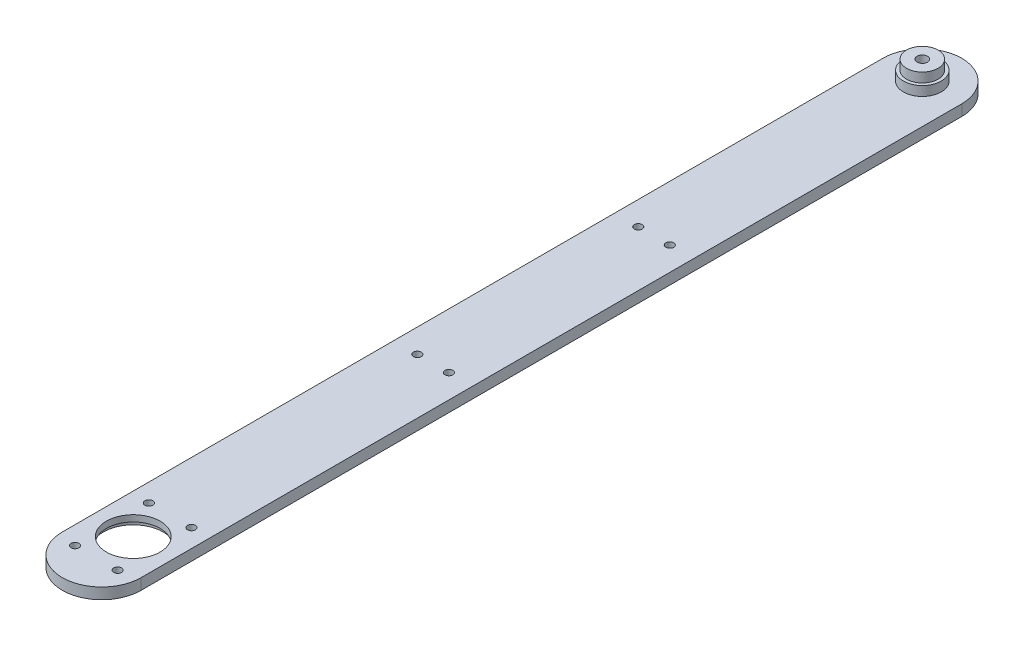
from build123d import *

# Parameters (mm, degrees)
EXTRUDE_1_DEPTH             = 10.5
EXTRUDE_1_DEPTH_BACK        = 10.5
SKETCH_1_R                  = 5
EXTRUDE_3_DEPTH             = 4.5
EXTRUDE_3_DEPTH_BACK        = 4.5
SKETCH_7_R                  = 6
EXTRUDE_4_DEPTH             = 3
EXTRUDE_START               = 3
SKETCH_8_R                  = 6
EXTRUDE_5_DEPTH             = 3
SKETCH_9_R                  = 9.5
CUT_EXTRUDE_1_DEPTH         = 7
SKETCH_10_R                 = 8.5
CUT_EXTRUDE_2_DEPTH         = 274.096136919
HOLE_WIZARD_M4_1_D          = 3.3
SKETCH_22_W                 = 46.630089335
SKETCH_22_H                 = 20.014444788
CUT_EXTRUDE_3_DEPTH         = 1111
HOLE_WIZARD_M3_2_D          = 2.5
PATTERN_LINEAR_1_COUNT      = 3
PATTERN_LINEAR_1_PITCH      = 70
PATTERN_LINEAR_1_COUNT_DIR2 = 2
PATTERN_LINEAR_1_PITCH_DIR2 = 10
HOLE_WIZARD_M3_1_D          = 2.5
PATTERN_CIRCULAR_1_COUNT    = 6
EXTRUDE_START_2             = -3.5
SKETCH_32_R                 = 1.25
EXTRUDE_6_DEPTH             = 3.5


with BuildPart() as part:
    # 스케치1 → 보스-돌출1 (new, two sides: drawn at the far end of the back side and taken through both)
    with BuildSketch(Plane(origin=(0, 0, 0), x_dir=(1, 0, 0), z_dir=(0, 1, 0)).offset(-EXTRUDE_1_DEPTH_BACK)):
        Circle(SKETCH_1_R)
    extrude(amount=EXTRUDE_1_DEPTH + EXTRUDE_1_DEPTH_BACK)

    # 스케치6 → 보스-돌출3 (add, two sides: drawn at the far end of the back side and taken through both)
    with BuildSketch(Plane(origin=(0, 0, 0), x_dir=(1, 0, 0), z_dir=(0, 1, 0)).offset(-EXTRUDE_3_DEPTH_BACK)):
        with BuildLine():
            Line((-12.5, 0), (-12.5, -260))
            ThreePointArc((-12.5, -260), (0, -272.5), (12.5, -260))
            Line((12.5, -260), (12.5, 0))
            ThreePointArc((12.5, 0), (0, 12.5), (-12.5, 0))
        make_face()
    extrude(amount=EXTRUDE_3_DEPTH + EXTRUDE_3_DEPTH_BACK)

    # 스케치7 → 보스-돌출4 (add)
    with BuildSketch(Plane.XZ.offset(4.5)):
        Circle(SKETCH_7_R)
    extrude(amount=EXTRUDE_4_DEPTH)

    # 스케치8 → 보스-돌출5 (add)
    with BuildSketch(Plane(origin=(0, 4.5, 0), x_dir=(1, 0, 0), z_dir=(0, 1, 0)).offset(EXTRUDE_START)):
        Circle(SKETCH_8_R)
    extrude(amount=-EXTRUDE_5_DEPTH)

    # 스케치9 → 컷-돌출1 (cut)
    with BuildSketch(Plane.XZ.offset(4.5)):
        with Locations((0, 250)):
            Circle(SKETCH_9_R)
    extrude(amount=-CUT_EXTRUDE_1_DEPTH, mode=Mode.SUBTRACT)

    # 스케치10 → 컷-돌출2 (cut, through all)
    with BuildSketch(Plane.XZ.offset(-2.5)):
        with Locations((0, 250)):
            Circle(SKETCH_10_R)
    extrude(amount=-CUT_EXTRUDE_2_DEPTH, mode=Mode.SUBTRACT)

    # M4 탭을 위한 탭 드릴1 (through all)
    with Locations(Plane(origin=(0, -10.5, 0), x_dir=(-1, 0, 0), z_dir=(0, -1, 0))):
        with Locations((0, 0)):
            Hole(HOLE_WIZARD_M4_1_D / 2)

    # 스케치22 → 컷-돌출3 (cut, symmetric)
    with BuildSketch(Plane.XY):
        with Locations((-0.058287612, -9.007222394)):
            Rectangle(SKETCH_22_W, SKETCH_22_H)
    extrude(amount=CUT_EXTRUDE_3_DEPTH, both=True, mode=Mode.SUBTRACT)

    # M3 탭을 위한 탭 드릴2 (through all)
    with Locations(Plane(origin=(0, 1, 0), x_dir=(-1, 0, 0), z_dir=(0, -1, 0))):
        with Locations((5, -15)):
            hole_wizard_m3_2 = Hole(HOLE_WIZARD_M3_2_D / 2)

    # 선형 패턴1: Hole Wizard M3 _ _ _ _2 3 × 2
    with Locations(*[(j * PATTERN_LINEAR_1_PITCH_DIR2, 0, i * PATTERN_LINEAR_1_PITCH) for i in range(PATTERN_LINEAR_1_COUNT) for j in range(PATTERN_LINEAR_1_COUNT_DIR2) if (i, j) != (0, 0)]):
        add(hole_wizard_m3_2, mode=Mode.SUBTRACT)

    # M3 탭을 위한 탭 드릴1 (through all)
    with Locations(Plane(origin=(0, 1, 0), x_dir=(-1, 0, 0), z_dir=(0, -1, 0))):
        with Locations((6.75, -261.691342951)):
            hole_wizard_m3_1 = Hole(HOLE_WIZARD_M3_1_D / 2)

    # 원형 패턴1: M3 탭을 위한 탭 드릴1 ×6 about axis, 2 skipped
    pattern_circular_1_axis = Axis((0, 2.5, 250), (0, -1, 0))
    add([hole_wizard_m3_1.rotate(pattern_circular_1_axis, i * 360 / PATTERN_CIRCULAR_1_COUNT) for i in range(1, PATTERN_CIRCULAR_1_COUNT) if i not in (1, 4)], mode=Mode.SUBTRACT)

    # 스케치32 → 보스-돌출6 (add)
    with BuildSketch(Plane.XZ.offset(-1).offset(EXTRUDE_START_2)):
        with Locations((-5, 15)):
            Circle(SKETCH_32_R)
        with Locations((5, 15)):
            Circle(SKETCH_32_R)
    extrude(amount=EXTRUDE_6_DEPTH)


solid = part.part
